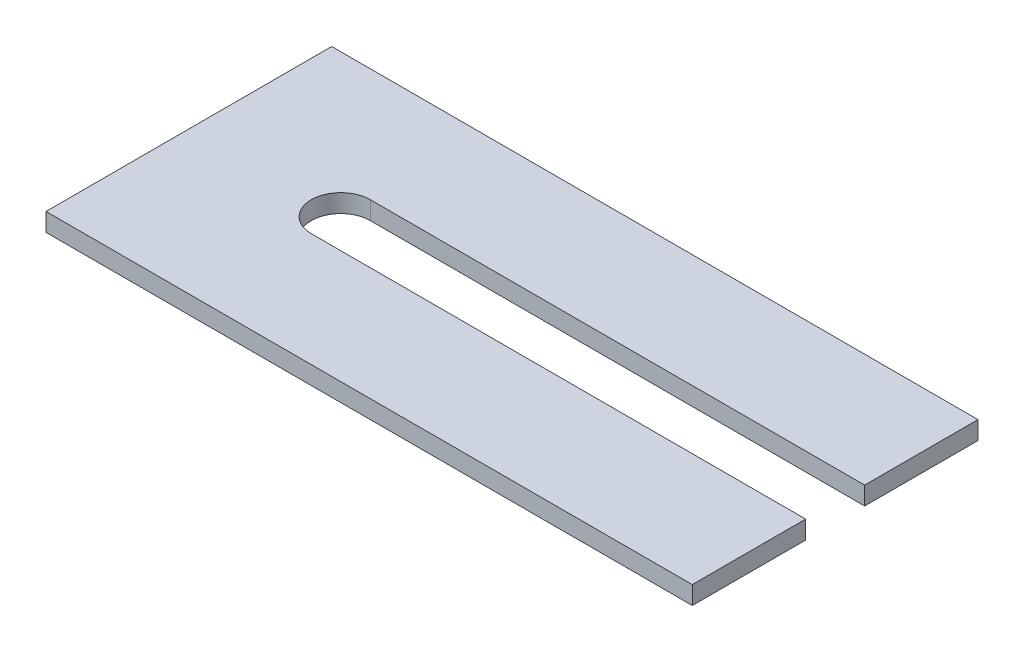
from build123d import *

# Parameters (mm, degrees)
BOSS_EXTRUDE1_DEPTH = 2


with BuildPart() as part:
    # Sketch1 → Boss-Extrude1 (new body)
    with BuildSketch(Plane(origin=(0, 0, 0), x_dir=(1, 0, 0), z_dir=(0, 1, 0))):
        with BuildLine():
            Line((0, 31.5), (0, 0))
            Line((0, 0), (71.25, 0))
            Line((71.25, 0), (71.25, 12.5))
            Line((71.25, 12.5), (16.75, 12.5))
            ThreePointArc((16.75, 12.5), (13.5, 15.75), (16.75, 19))
            Line((16.75, 19), (71.25, 19))
            Line((71.25, 19), (71.25, 31.5))
            Line((71.25, 31.5), (0, 31.5))
        make_face()
    extrude(amount=BOSS_EXTRUDE1_DEPTH)


solid = part.part
